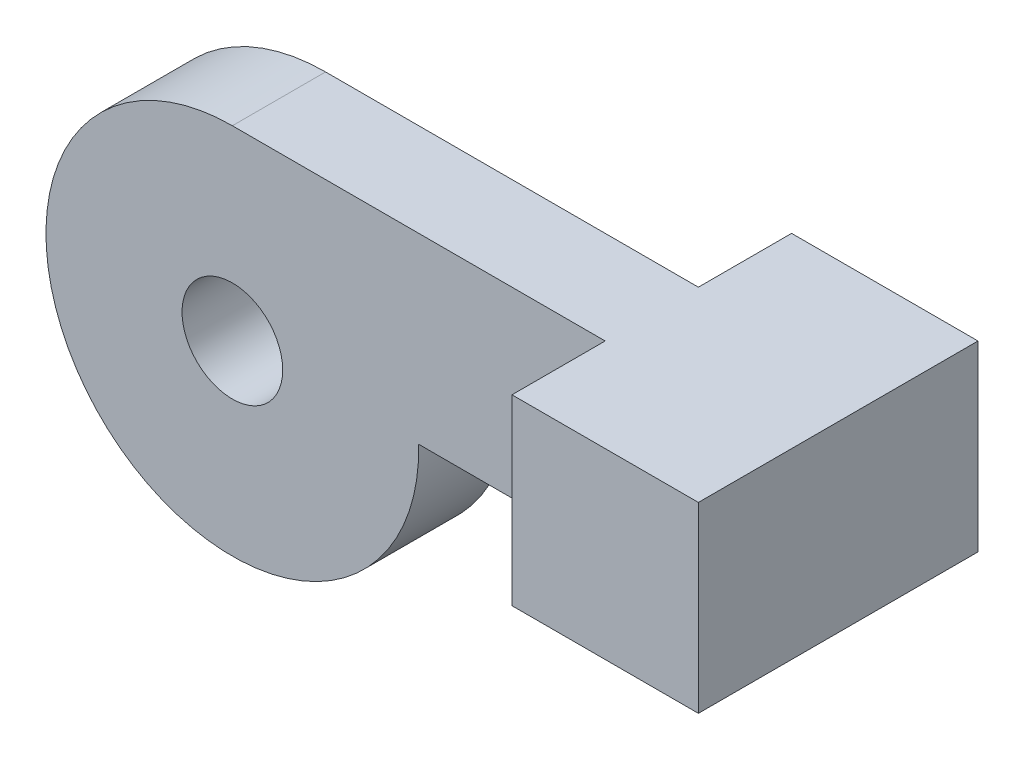
from build123d import *

# Parameters (mm, degrees)
SKETCH1_R           = 3.429
BOSS_EXTRUDE1_DEPTH = 3.175
SKETCH2_W           = 12.7
SKETCH2_H           = 12.446
BOSS_EXTRUDE2_DEPTH = 9.525


with BuildPart() as part:
    # Sketch1 → Boss-Extrude1 (new body, symmetric)
    with BuildSketch(Plane.XY):
        with BuildLine():
            Line((0, 12.7), (38.1, 12.7))
            Line((38.1, 12.7), (38.1, 0.254))
            Line((38.1, 0.254), (12.697459746, 0.254))
            ThreePointArc((12.697459746, 0.254), (-8.89, -9.069614104), (0, 12.7))
        make_face()
        Circle(SKETCH1_R, mode=Mode.SUBTRACT)
    extrude(amount=BOSS_EXTRUDE1_DEPTH, both=True)

    # Sketch2 → Boss-Extrude2 (add, symmetric)
    with BuildSketch(Plane.XY):
        with Locations((31.75, 6.477)):
            Rectangle(SKETCH2_W, SKETCH2_H)
    extrude(amount=BOSS_EXTRUDE2_DEPTH, both=True)


solid = part.part
